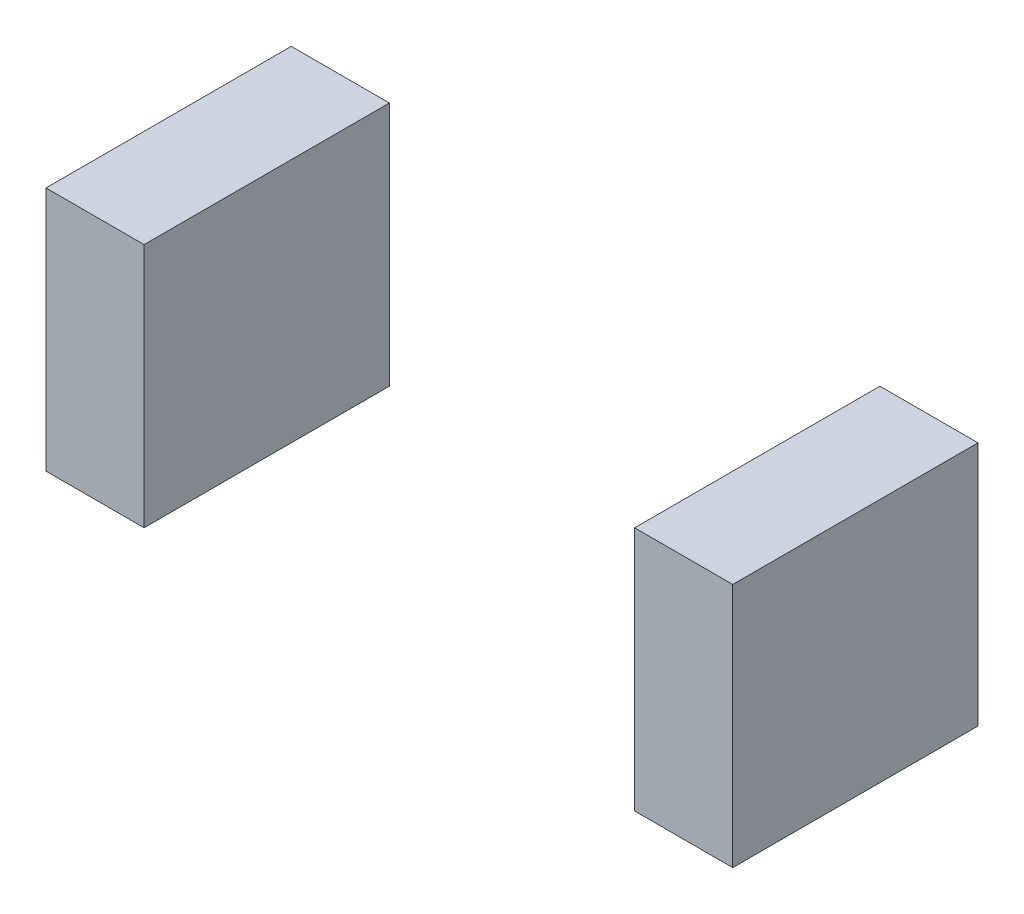
from build123d import *

# Parameters (mm, degrees)
SZKIC1_W                    = 20
SZKIC1_H                    = 50
DODANIE_WYCI_GNI_CIE1_DEPTH = 50
SZYK_LINIOWY1_COUNT         = 2
SZYK_LINIOWY1_PITCH         = 120


with BuildPart() as part:
    # Szkic1 → Dodanie-wyciągnięcie1 (new body)
    with BuildSketch(Plane.XY):
        with Locations((10, 25)):
            Rectangle(SZKIC1_W, SZKIC1_H)
    extrude(amount=DODANIE_WYCI_GNI_CIE1_DEPTH)


with BuildPart() as szyk_liniowy1_1:
    # Szyk liniowy1: pattern copy
    add(part.part.moved(Location(Vector(1, 0, 0) * (1 * SZYK_LINIOWY1_PITCH))))


solid = Compound([part.part, szyk_liniowy1_1.part])
